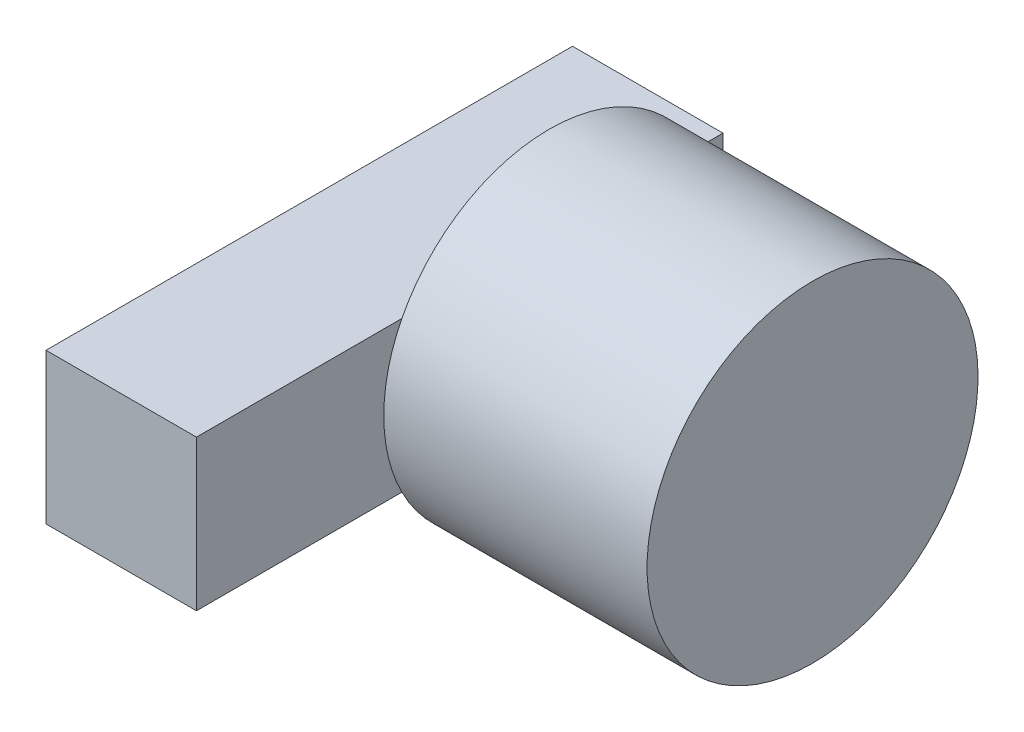
from build123d import *

# Parameters (mm, degrees)
SKIZZE3_W                       = 20
SKIZZE3_H                       = 20
AUFSATZ_LINEAR_AUSTRAGEN2_DEPTH = 70
SKIZZE4_R                       = 22
AUFSATZ_LINEAR_AUSTRAGEN3_DEPTH = 35


with BuildPart() as part:
    # Skizze3 → Aufsatz-Linear austragen2 (new body)
    with BuildSketch(Plane.XY):
        Rectangle(SKIZZE3_W, SKIZZE3_H)
    extrude(amount=AUFSATZ_LINEAR_AUSTRAGEN2_DEPTH)

    # Skizze4 → Aufsatz-Linear austragen3 (add)
    with BuildSketch(Plane(origin=(10, 0, 0), x_dir=(0, 0, -1), z_dir=(1, 0, 0))):
        with Locations((-23.092221055, 0)):
            Circle(SKIZZE4_R)
    extrude(amount=AUFSATZ_LINEAR_AUSTRAGEN3_DEPTH)


solid = part.part
